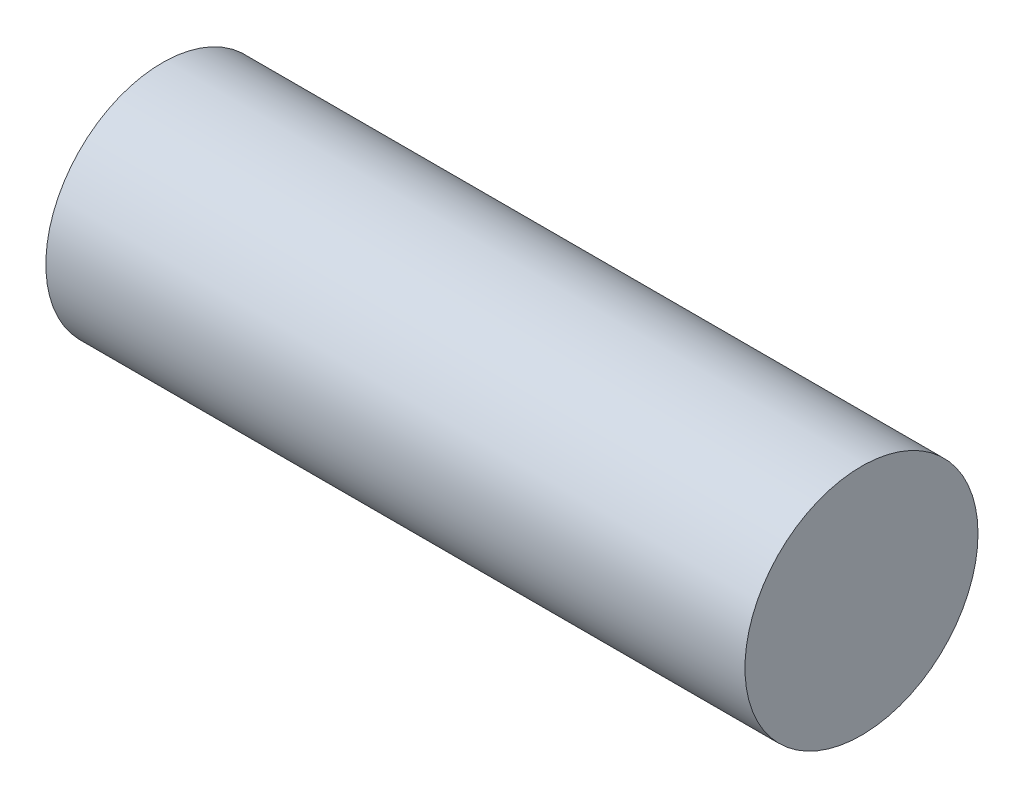
from build123d import *

# Parameters (mm, degrees)
SKETCH1_R           = 0.635
BOSS_EXTRUDE1_DEPTH = 3.81


with BuildPart() as part:
    # Sketch1 → Boss-Extrude1 (new body)
    with BuildSketch(Plane(origin=(0, 0, 0), x_dir=(0, 0, -1), z_dir=(1, 0, 0))):
        Circle(SKETCH1_R)
    extrude(amount=BOSS_EXTRUDE1_DEPTH)


solid = part.part
